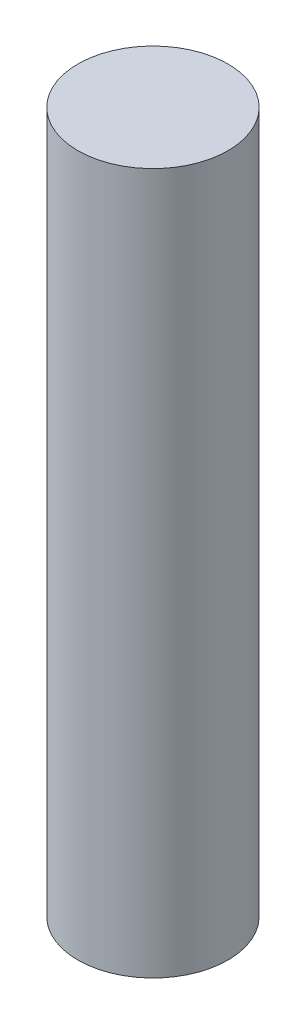
from build123d import *

# Parameters (mm, degrees)
SKETCH1_R           = 7.5
BOSS_EXTRUDE1_DEPTH = 70
SCALE1_SCALE        = 10
SCALE2_SCALE        = 0.75


with BuildPart() as part:
    # Sketch1 → Boss-Extrude1 (new body)
    with BuildSketch(Plane(origin=(0, 0, 0), x_dir=(1, 0, 0), z_dir=(0, 1, 0))):
        Circle(SKETCH1_R)
    extrude(amount=BOSS_EXTRUDE1_DEPTH)


with BuildPart() as part_1:
    # Scale1: scaled about (0, 0, 0)
    add(part.part.scale(SCALE1_SCALE))


with BuildPart() as part_2:
    # Scale2: scaled about (0, 350, 0)
    add(part_1.part.scale(SCALE2_SCALE).moved(Location((0, 87.5, 0))))


solid = part_2.part
